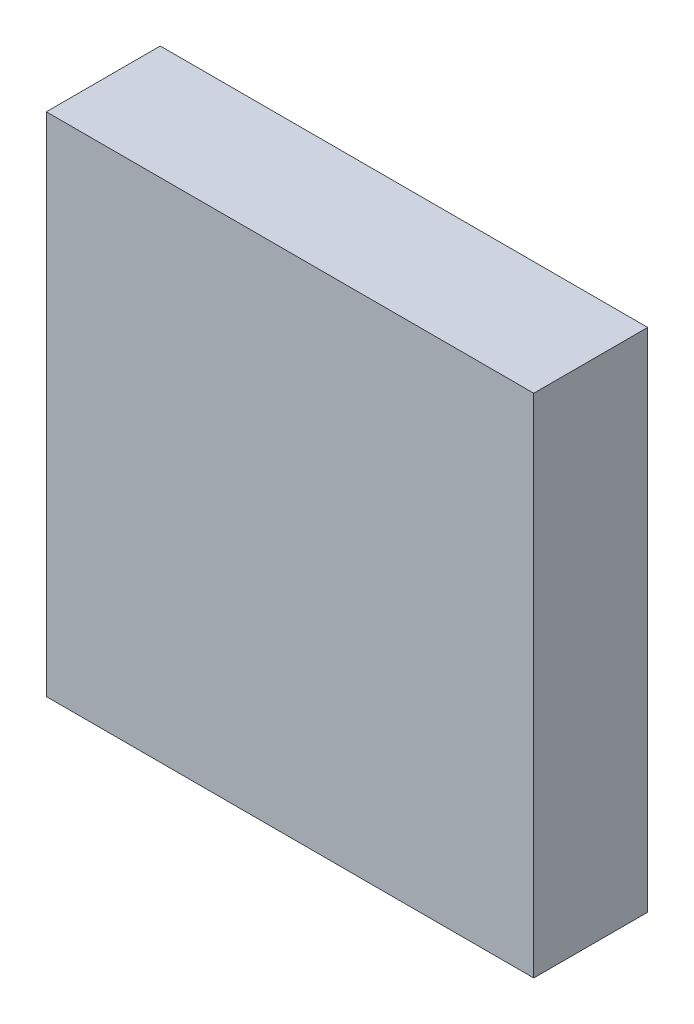
from build123d import *

# Parameters (mm, degrees)
SKETCH1_W           = 38.5
SKETCH1_H           = 40
BOSS_EXTRUDE1_DEPTH = 4.5


with BuildPart() as part:
    # Sketch1 → Boss-Extrude1 (new body, symmetric)
    with BuildSketch(Plane.XY):
        Rectangle(SKETCH1_W, SKETCH1_H)
    extrude(amount=BOSS_EXTRUDE1_DEPTH, both=True)


solid = part.part
